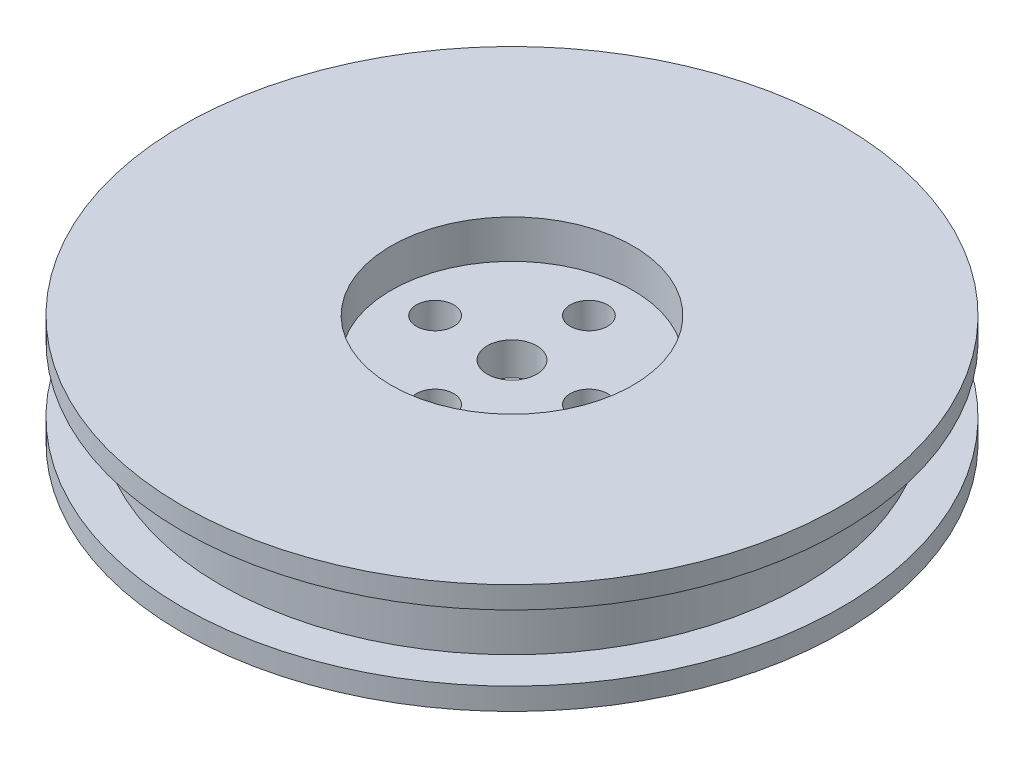
from build123d import *

# Parameters (mm, degrees)
SKETCH1_R           = 30
EXTRUDE_C_DEPTH     = 2
SKETCH2_R           = 26.5
BOSS_EXTRUDE2_DEPTH = 6
SKETCH3_R           = 30
BOSS_EXTRUDE3_DEPTH = 2
SKETCH8_R           = 11
CUT_EXTRUDE2_DEPTH  = 3.5
SKETCH9_R           = 11
CUT_EXTRUDE3_DEPTH  = 3.5
SKETCH10_R          = 2.25
CUT_EXTRUDE4_DEPTH  = 12.5
SKETCH12_R          = 1.7
CUT_EXTRUDE5_DEPTH  = 10


with BuildPart() as part:
    # Sketch1 → Extrude c (new body)
    with BuildSketch(Plane(origin=(0, 0, 0), x_dir=(1, 0, 0), z_dir=(0, 1, 0))):
        Circle(SKETCH1_R)
    extrude(amount=EXTRUDE_C_DEPTH)

    # Sketch2 → Boss-Extrude2 (add)
    with BuildSketch(Plane(origin=(0, 2, 0), x_dir=(1, 0, 0), z_dir=(0, 1, 0))):
        Circle(SKETCH2_R)
    extrude(amount=BOSS_EXTRUDE2_DEPTH)

    # Sketch3 → Boss-Extrude3 (add)
    with BuildSketch(Plane(origin=(0, 8, 0), x_dir=(1, 0, 0), z_dir=(0, 1, 0))):
        Circle(SKETCH3_R)
    extrude(amount=BOSS_EXTRUDE3_DEPTH)

    # Sketch8 → Cut-Extrude2 (cut)
    with BuildSketch(Plane.XZ):
        Circle(SKETCH8_R)
    extrude(amount=-CUT_EXTRUDE2_DEPTH, mode=Mode.SUBTRACT)

    # Sketch9 → Cut-Extrude3 (cut)
    with BuildSketch(Plane(origin=(0, 10, 0), x_dir=(1, 0, 0), z_dir=(0, 1, 0))):
        Circle(SKETCH9_R)
    extrude(amount=-CUT_EXTRUDE3_DEPTH, mode=Mode.SUBTRACT)

    # Sketch10 → Cut-Extrude4 (cut)
    with BuildSketch(Plane(origin=(0, 6.5, 0), x_dir=(1, 0, 0), z_dir=(0, 1, 0))):
        Circle(SKETCH10_R)
    extrude(amount=-CUT_EXTRUDE4_DEPTH, mode=Mode.SUBTRACT)

    # Sketch12 → Cut-Extrude5 (cut)
    with BuildSketch(Plane(origin=(0, 6.5, 0), x_dir=(1, 0, 0), z_dir=(0, 1, 0))):
        with Locations((0, 7)):
            Circle(SKETCH12_R)
        with Locations((7, 0)):
            Circle(SKETCH12_R)
        with Locations((0, -7)):
            Circle(SKETCH12_R)
        with Locations((-7, 0)):
            Circle(SKETCH12_R)
    extrude(amount=-CUT_EXTRUDE5_DEPTH, mode=Mode.SUBTRACT)


solid = part.part
